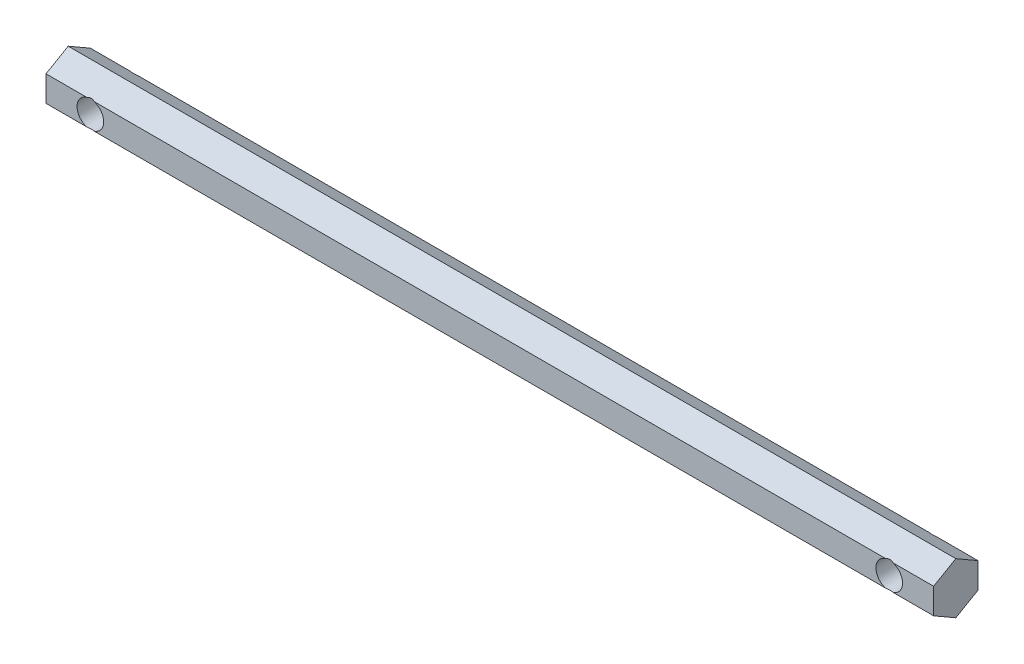
from build123d import *

# Parameters (mm, degrees)
BOSS_EXTRUDE1_DEPTH     = 100
SKETCH2_R               = 3
CUT_EXTRUDE1_DEPTH      = 6
CUT_EXTRUDE1_DEPTH_BACK = 6


with BuildPart() as part:
    # Sketch1 → Boss-Extrude1 (new body, symmetric)
    with BuildSketch(Plane(origin=(0, 0, 0), x_dir=(0, 0, -1), z_dir=(1, 0, 0))):
        Polygon((0, 5.773502692), (-5, 2.886751346), (-5, -2.886751346), (0, -5.773502692), (5, -2.886751346), (5, 2.886751346), align=None)
    extrude(amount=BOSS_EXTRUDE1_DEPTH, both=True)

    # Sketch2 → Cut-Extrude1 (cut, two sides)
    with BuildSketch(Plane.XY) as cut_extrude1_sk:
        with Locations((90, 0)):
            Circle(SKETCH2_R)
        with Locations((-90, 0)):
            Circle(SKETCH2_R)
    extrude(amount=CUT_EXTRUDE1_DEPTH, mode=Mode.SUBTRACT)
    extrude(cut_extrude1_sk.sketch, amount=-CUT_EXTRUDE1_DEPTH_BACK, mode=Mode.SUBTRACT)


solid = part.part
